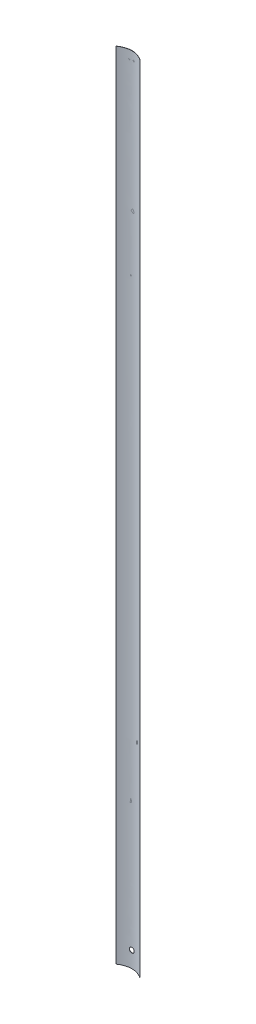
from build123d import *

# Parameters (mm, degrees)
BOSS_EXTRUDE1_DEPTH = 495
SKETCH2_R           = 1.5
CUT_EXTRUDE4_DEPTH  = 3.5500001


with BuildPart() as part:
    # Sketch1 → Boss-Extrude1 (new body)
    with BuildSketch(Plane(origin=(0, 0, 0), x_dir=(1, 0, 0), z_dir=(0, 1, 0))):
        with BuildLine():
            Line((7.55, -2.55), (7.45, -2.55))
            add(Edge.make_bspline(
                [(-7.45, -2.55), (0, 2.35), (7.45, -2.55)],
                knots=[0, 0, 0, 1, 1, 1], degree=2))
            Line((-7.45, -2.55), (-7.55, -2.55))
            add(Edge.make_bspline(
                [(7.55, -2.55), (0, 2.55), (-7.55, -2.55)],
                knots=[0, 0, 0, 1, 1, 1], degree=2))
        make_face()
    extrude(amount=BOSS_EXTRUDE1_DEPTH)

    # Sketch2 → Cut-Extrude4 (cut, through all)
    with BuildSketch(Plane.XY):
        with Locations((0, 10)):
            Circle(SKETCH2_R)
    extrude(amount=CUT_EXTRUDE4_DEPTH, mode=Mode.SUBTRACT)


solid = part.part
